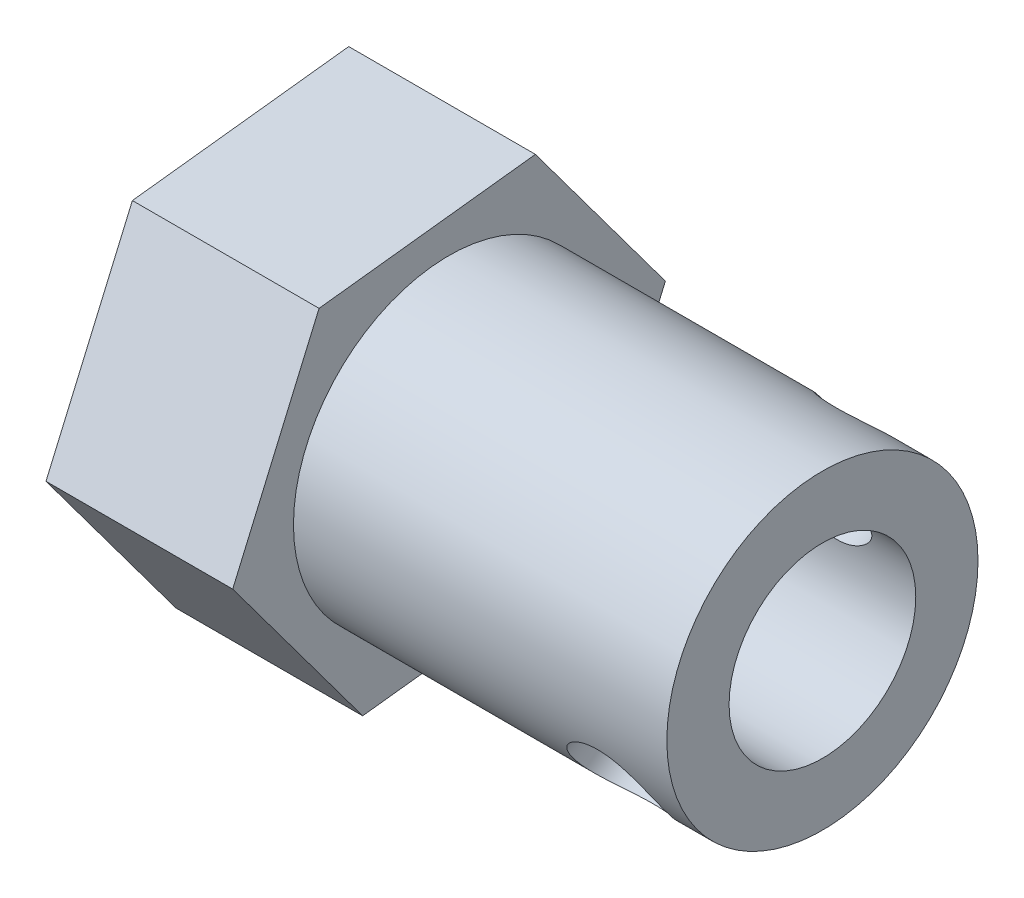
from build123d import *

# Parameters (mm, degrees)
SKETCH1_R           = 5
SKETCH1_R_2         = 3
BOSS_EXTRUDE1_DEPTH = 18
BOSS_EXTRUDE2_DEPTH = 6
SKETCH3_R           = 2
CUT_EXTRUDE1_DEPTH  = 6
SKETCH4_R           = 1.5
CUT_EXTRUDE2_DEPTH  = 14


with BuildPart() as part:
    # Sketch1 → Boss-Extrude1 (new body)
    with BuildSketch(Plane(origin=(0, 0, 0), x_dir=(0, 0, -1), z_dir=(1, 0, 0))):
        Circle(SKETCH1_R)
        Circle(SKETCH1_R_2, mode=Mode.SUBTRACT)
    extrude(amount=BOSS_EXTRUDE1_DEPTH)

    # Sketch2 → Boss-Extrude2 (add)
    with BuildSketch(Plane.ZY):
        Polygon((-6.953065422, 0.809247324), (-4.177361452, -5.616907628), (2.775703971, -6.426154952), (6.953065422, -0.809247324), (4.177361452, 5.616907628), (-2.775703971, 6.426154952), align=None)
    extrude(amount=-BOSS_EXTRUDE2_DEPTH)

    # Sketch3 → Cut-Extrude1 (cut)
    with BuildSketch(Plane.ZY):
        Circle(SKETCH3_R)
    extrude(amount=-CUT_EXTRUDE1_DEPTH, mode=Mode.SUBTRACT)

    # Sketch4 → Cut-Extrude2 (cut)
    with BuildSketch(Plane(origin=(0, 3.617701138, -4.864384697), x_dir=(-1, 0, 0), z_dir=(0, 0.596765922, -0.802415375))):
        with Locations((-15.5, 0)):
            Circle(SKETCH4_R)
    extrude(amount=-CUT_EXTRUDE2_DEPTH, mode=Mode.SUBTRACT)


solid = part.part
